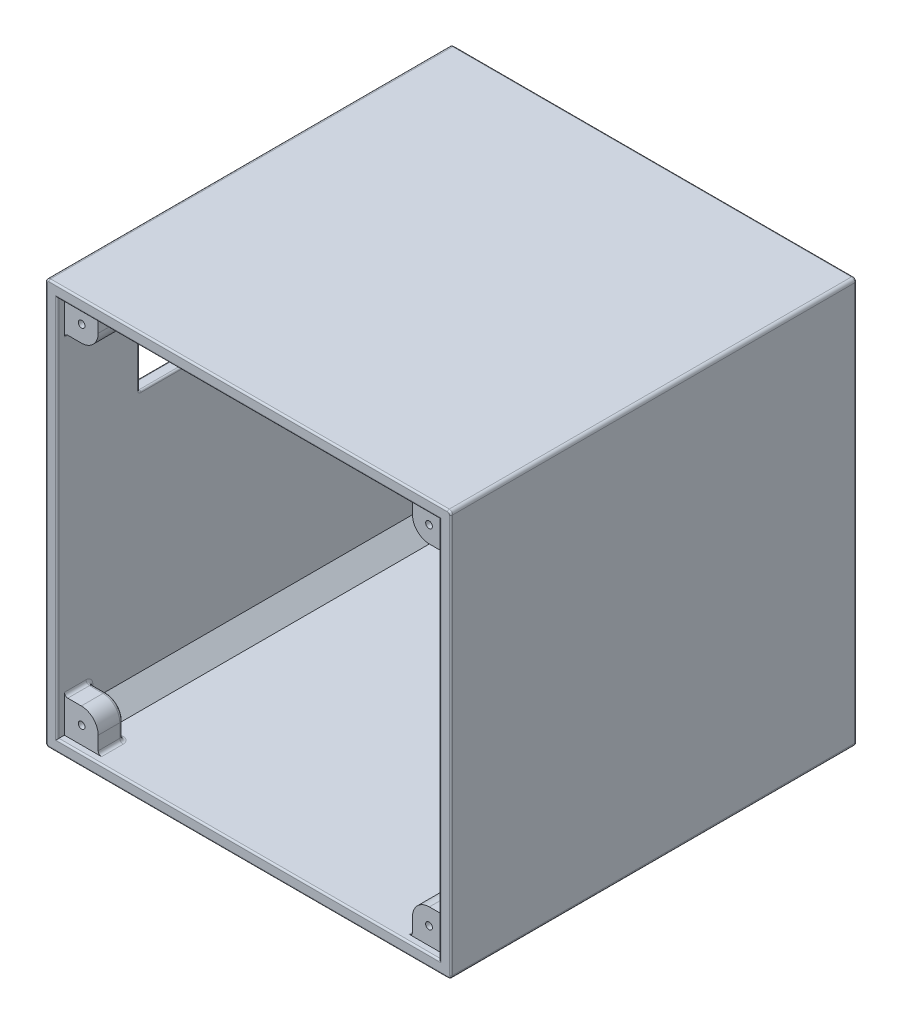
from build123d import *

# Parameters (mm, degrees)
ESBO_O2_W                     = 120
ESBO_O2_H                     = 120
RESSALTO_EXTRUS_O1_DEPTH      = 120
ESBO_O3_W                     = 113
ESBO_O3_H                     = 113
CORTE_EXTRUS_O1_DEPTH         = 120
RESSALTO_EXTRUS_O2_DEPTH      = 7
RESSALTO_EXTRUS_O6_DEPTH      = 7
CHANFRO1_SIZE                 = 5
CHANFRO2_SIZE                 = 5
ESBO_O14_W                    = 71.5
ESBO_O14_H                    = 24.5
CORTE_EXTRUS_O6_DEPTH         = 10
ESBO_O15_W                    = 113
ESBO_O15_H                    = 113
CORTE_EXTRUS_O7_DEPTH         = 5
FILETE3_R                     = 1
FILETE4_R                     = 1
RESSALTO_EXTRUS_O7_DEPTH      = 1.4
RESSALTO_EXTRUS_O7_DEPTH_BACK = 6
FILETE8_R                     = 1
ESBO_O16_R                    = 1
CORTE_EXTRUS_O8_DEPTH         = 7.4
ESPELHAR2_COPY_1_SKETCH_R     = 1
ESPELHAR2_COPY_1_DEPTH        = 7.4
ESBO_O17_R                    = 1.75
CORTE_EXTRUS_O9_DEPTH         = 7
ESBO_O18_R                    = 3.6
CORTE_EXTRUS_O10_DEPTH        = 1
ESPELHAR6_COPY_1_SKETCH_R     = 1.75
ESPELHAR6_COPY_1_DEPTH        = 7
ESPELHAR6_COPY_2_SKETCH_R     = 3.6
ESPELHAR6_COPY_2_DEPTH        = 1
ESBO_O19_R                    = 3.6
CORTE_EXTRUS_O12_DEPTH        = 0.5
ESBO_O21_R                    = 1.75
CORTE_EXTRUS_O13_DEPTH        = 7.5
FILETE9_R                     = 0.5


with BuildPart() as part:
    # Esboço2 → Ressalto-extrusão1 (new body)
    with BuildSketch(Plane.XY):
        Rectangle(ESBO_O2_W, ESBO_O2_H)
    extrude(amount=RESSALTO_EXTRUS_O1_DEPTH)

    # Esboço3 → Corte-extrusão1 (cut)
    with BuildSketch(Plane.XY.offset(120)):
        Rectangle(ESBO_O3_W, ESBO_O3_H)
    extrude(amount=-CORTE_EXTRUS_O1_DEPTH, mode=Mode.SUBTRACT)

    # Esboço4 → Ressalto-extrusão2 (add)
    with BuildSketch(Plane.XY):
        with BuildLine():
            Line((-51.5, 46.5), (-56.5, 46.5))
            Line((-56.5, 46.5), (-56.5, 56.5))
            Line((-56.5, 56.5), (-46.5, 56.5))
            Line((-46.5, 56.5), (-46.5, 51.5))
            ThreePointArc((-46.5, 51.5), (-47.964466094, 47.964466094), (-51.5, 46.5))
        make_face()
        with BuildLine():
            Line((46.5, 56.5), (46.5, 51.5))
            ThreePointArc((46.5, 51.5), (47.964466094, 47.964466094), (51.5, 46.5))
            Line((51.5, 46.5), (56.5, 46.5))
            Line((56.5, 46.5), (56.5, 56.5))
            Line((56.5, 56.5), (46.5, 56.5))
        make_face()
        with BuildLine():
            Line((51.5, -46.5), (56.5, -46.5))
            Line((56.5, -46.5), (56.5, -56.5))
            Line((56.5, -56.5), (46.5, -56.5))
            Line((46.5, -56.5), (46.5, -51.5))
            ThreePointArc((46.5, -51.5), (47.964466094, -47.964466094), (51.5, -46.5))
        make_face()
        with BuildLine():
            Line((-46.5, -56.5), (-46.5, -51.5))
            ThreePointArc((-46.5, -51.5), (-47.964466094, -47.964466094), (-51.5, -46.5))
            Line((-51.5, -46.5), (-56.5, -46.5))
            Line((-56.5, -46.5), (-56.5, -56.5))
            Line((-56.5, -56.5), (-46.5, -56.5))
        make_face()
        with BuildLine():
            Line((-51.5, 5), (-56.5, 5))
            Line((-56.5, 5), (-56.5, -5))
            Line((-56.5, -5), (-51.5, -5))
            ThreePointArc((-51.5, -5), (-46.5, 0), (-51.5, 5))
        make_face()
        with BuildLine():
            Line((56.5, -5), (51.5, -5))
            ThreePointArc((51.5, -5), (46.5, 0), (51.5, 5))
            Line((51.5, 5), (56.5, 5))
            Line((56.5, 5), (56.5, -5))
        make_face()
        with BuildLine():
            Line((-5, 51.5), (-5, 56.5))
            Line((-5, 56.5), (5, 56.5))
            Line((5, 56.5), (5, 51.5))
            ThreePointArc((5, 51.5), (0, 46.5), (-5, 51.5))
        make_face()
    extrude(amount=RESSALTO_EXTRUS_O2_DEPTH)

    # Esboço13 → Ressalto-extrusão6 (add)
    with BuildSketch(Plane.XY):
        with BuildLine():
            Line((-5, -51.5), (-5, -56.5))
            Line((-5, -56.5), (5, -56.5))
            Line((5, -56.5), (5, -51.5))
            ThreePointArc((5, -51.5), (0, -46.5), (-5, -51.5))
        make_face()
    extrude(amount=RESSALTO_EXTRUS_O6_DEPTH)

    # Chanfro1
    chanfro1_edges = [part.edges().sort_by_distance(p)[0] for p in [
        (-56.5, 56.5, 63.5),
    ]]
    chamfer(chanfro1_edges, length=CHANFRO1_SIZE)

    # Chanfro2
    chanfro2_edges = [part.edges().sort_by_distance(p)[0] for p in [
        (56.5, 56.5, 63.5),
        (56.5, -56.5, 63.5),
        (-56.5, -56.5, 63.5),
    ]]
    chamfer(chanfro2_edges, length=CHANFRO2_SIZE)

    # Esboço14 → Corte-extrusão6 (cut)
    with BuildSketch(Plane.ZY.offset(60)):
        with Locations((60, 32.75)):
            Rectangle(ESBO_O14_W, ESBO_O14_H)
    extrude(amount=-CORTE_EXTRUS_O6_DEPTH, mode=Mode.SUBTRACT)

    # Esboço15 → Corte-extrusão7 (cut)
    with BuildSketch(Plane.XY.offset(120)):
        Rectangle(ESBO_O15_W, ESBO_O15_H)
    extrude(amount=-CORTE_EXTRUS_O7_DEPTH, mode=Mode.SUBTRACT)

    # Filete3
    filete3_edges = [part.edges().sort_by_distance(p)[0] for p in [
        (-60, 60, 60),
    ]]
    fillet(filete3_edges, radius=FILETE3_R)

    # Filete4
    filete4_edges = [part.edges().sort_by_distance(p)[0] for p in [
        (60, -60, 60),
        (-60, -60, 60),
        (60, 60, 60),
    ]]
    fillet(filete4_edges, radius=FILETE4_R)

    # Esboço5 → Ressalto-extrusão7 (add, two sides)
    with BuildSketch(Plane.XY.offset(116.5)) as ressalto_extrus_o7_sk:
        with BuildLine():
            Line((-51.5, 46.5), (-56.5, 46.5))
            Line((-56.5, 46.5), (-56.5, 56.5))
            Line((-56.5, 56.5), (-46.5, 56.5))
            Line((-46.5, 56.5), (-46.5, 51.5))
            ThreePointArc((-46.5, 51.5), (-47.964466094, 47.964466094), (-51.5, 46.5))
        make_face()
        with BuildLine():
            Line((46.5, 56.5), (46.5, 51.5))
            ThreePointArc((46.5, 51.5), (47.964466094, 47.964466094), (51.5, 46.5))
            Line((51.5, 46.5), (56.5, 46.5))
            Line((56.5, 46.5), (56.5, 56.5))
            Line((56.5, 56.5), (46.5, 56.5))
        make_face()
        with BuildLine():
            Line((51.5, -46.5), (56.5, -46.5))
            Line((56.5, -46.5), (56.5, -56.5))
            Line((56.5, -56.5), (46.5, -56.5))
            Line((46.5, -56.5), (46.5, -51.5))
            ThreePointArc((46.5, -51.5), (47.964466094, -47.964466094), (51.5, -46.5))
        make_face()
        with BuildLine():
            Line((-46.5, -56.5), (-46.5, -51.5))
            ThreePointArc((-46.5, -51.5), (-47.964466094, -47.964466094), (-51.5, -46.5))
            Line((-51.5, -46.5), (-56.5, -46.5))
            Line((-56.5, -46.5), (-56.5, -56.5))
            Line((-56.5, -56.5), (-46.5, -56.5))
        make_face()
    extrude(amount=RESSALTO_EXTRUS_O7_DEPTH)
    extrude(ressalto_extrus_o7_sk.sketch, amount=-RESSALTO_EXTRUS_O7_DEPTH_BACK)

    # Filete8
    filete8_edges = [part.edges().sort_by_distance(p)[0] for p in [
        (56.5, -5, 3.5),
        (56.5, 5, 3.5),
        (46.5, 0, 7),
        (54, -5, 7),
        (56.5, 0, 7),
        (54, 5, 7),
        (5, 56.5, 3.5),
        (-5, 56.5, 3.5),
        (5, 54, 7),
        (0, 56.5, 7),
        (-5, 54, 7),
        (0, 46.5, 7),
        (-5, -56.5, 3.5),
        (5, -56.5, 3.5),
        (0, -46.5, 7),
        (-5, -54, 7),
        (0, -56.5, 7),
        (5, -54, 7),
        (-56.5, 49, 7),
        (-54, 54, 7),
        (-49, -56.5, 7),
        (-54, -54, 7),
        (56.5, -49, 7),
        (54, -54, 7),
        (49, 56.5, 7),
        (54, 54, 7),
        (-54, 54, 110.5),
        (-49, 56.5, 110.5),
        (-46.5, 56.5, 114.2),
        (-56.5, 49, 110.5),
        (-47.964466094, 47.964466094, 110.5),
        (-46.5, 54, 110.5),
        (-56.5, 46.5, 114.2),
        (-54, 46.5, 110.5),
        (54, 54, 110.5),
        (56.5, 49, 110.5),
        (56.5, 46.5, 114.2),
        (49, 56.5, 110.5),
        (47.964466094, 47.964466094, 110.5),
        (54, 46.5, 110.5),
        (46.5, 56.5, 114.2),
        (46.5, 54, 110.5),
        (54, -54, 110.5),
        (49, -56.5, 110.5),
        (46.5, -56.5, 114.2),
        (56.5, -49, 110.5),
        (47.964466094, -47.964466094, 110.5),
        (46.5, -54, 110.5),
        (56.5, -46.5, 114.2),
        (54, -46.5, 110.5),
        (-54, -54, 110.5),
        (-56.5, -49, 110.5),
        (-56.5, -46.5, 114.2),
        (-49, -56.5, 110.5),
        (-47.964466094, -47.964466094, 110.5),
        (-54, -46.5, 110.5),
        (-46.5, -56.5, 114.2),
        (-46.5, -54, 110.5),
        (-46.5, 56.5, 3.5),
        (-56.5, 46.5, 3.5),
        (-47.964466094, 47.964466094, 7),
        (-46.5, 54, 7),
        (-49, 56.5, 7),
        (-54, 46.5, 7),
        (56.5, 46.5, 3.5),
        (46.5, 56.5, 3.5),
        (47.964466094, 47.964466094, 7),
        (54, 46.5, 7),
        (56.5, 49, 7),
        (46.5, 54, 7),
        (46.5, -56.5, 3.5),
        (56.5, -46.5, 3.5),
        (47.964466094, -47.964466094, 7),
        (46.5, -54, 7),
        (49, -56.5, 7),
        (54, -46.5, 7),
        (-56.5, -46.5, 3.5),
        (-46.5, -56.5, 3.5),
        (-47.964466094, -47.964466094, 7),
        (-54, -46.5, 7),
        (-56.5, -49, 7),
        (-46.5, -54, 7),
        (-56.5, 5, 3.5),
        (-56.5, -5, 3.5),
        (-46.5, 0, 7),
        (-54, 5, 7),
        (-56.5, 0, 7),
        (-54, -5, 7),
    ]]
    fillet(filete8_edges, radius=FILETE8_R)

    # Esboço16 → Corte-extrusão8 (cut)
    with BuildSketch(Plane.XY.offset(117.9)):
        with Locations((-51.4, 51.4)):
            Circle(ESBO_O16_R)
    corte_extrus_o8 = extrude(amount=-CORTE_EXTRUS_O8_DEPTH, mode=Mode.SUBTRACT)

    # Espelhar1: Corte-extrusão8 across plane
    add(corte_extrus_o8.mirror(Plane.ZX), mode=Mode.SUBTRACT)

    # Espelhar2: Corte-extrusão8 across plane
    add(corte_extrus_o8.mirror(Plane(origin=(0, 0, 0), x_dir=(0, 0, 1), z_dir=(1, 0, 0))), mode=Mode.SUBTRACT)

    # Espelhar2 copy 1 sketch → Espelhar2 copy 1 (cut)
    with BuildSketch(Plane(origin=(0, 0, 117.9), x_dir=(-1, 0, 0), z_dir=(0, 0, 1))):
        with Locations((-51.4, 51.4)):
            Circle(ESPELHAR2_COPY_1_SKETCH_R)
    extrude(amount=-ESPELHAR2_COPY_1_DEPTH, mode=Mode.SUBTRACT)

    # Esboço17 → Corte-extrusão9 (cut)
    with BuildSketch(Plane.XY.offset(7)):
        with Locations((-51.4, 51.4)):
            Circle(ESBO_O17_R)
    corte_extrus_o9 = extrude(amount=-CORTE_EXTRUS_O9_DEPTH, mode=Mode.SUBTRACT)

    # Esboço18 → Corte-extrusão10 (cut, symmetric)
    with BuildSketch(Plane.XY.offset(7)):
        with Locations((-51.4, 51.4)):
            Circle(ESBO_O18_R)
    corte_extrus_o10 = extrude(amount=CORTE_EXTRUS_O10_DEPTH, both=True, mode=Mode.SUBTRACT)

    # Espelhar5: Corte-extrusão9, Corte-extrusão10 across plane
    add(corte_extrus_o9.mirror(Plane.ZX), mode=Mode.SUBTRACT)
    add(corte_extrus_o10.mirror(Plane.ZX), mode=Mode.SUBTRACT)

    # Espelhar6: Corte-extrusão9, Corte-extrusão10 across plane
    add(corte_extrus_o9.mirror(Plane(origin=(0, 0, 0), x_dir=(0, 0, 1), z_dir=(1, 0, 0))), mode=Mode.SUBTRACT)
    add(corte_extrus_o10.mirror(Plane(origin=(0, 0, 0), x_dir=(0, 0, 1), z_dir=(1, 0, 0))), mode=Mode.SUBTRACT)

    # Espelhar6 copy 1 sketch → Espelhar6 copy 1 (cut)
    with BuildSketch(Plane(origin=(0, 0, 7), x_dir=(-1, 0, 0), z_dir=(0, 0, 1))):
        with Locations((-51.4, 51.4)):
            Circle(ESPELHAR6_COPY_1_SKETCH_R)
    extrude(amount=-ESPELHAR6_COPY_1_DEPTH, mode=Mode.SUBTRACT)

    # Espelhar6 copy 2 sketch → Espelhar6 copy 2 (cut, symmetric)
    with BuildSketch(Plane(origin=(0, 0, 7), x_dir=(-1, 0, 0), z_dir=(0, 0, 1))):
        with Locations((-51.4, 51.4)):
            Circle(ESPELHAR6_COPY_2_SKETCH_R)
    extrude(amount=ESPELHAR6_COPY_2_DEPTH, both=True, mode=Mode.SUBTRACT)

    # Esboço19 → Corte-extrusão12 (cut)
    with BuildSketch(Plane.XY.offset(7)):
        with Locations((-51.4, 0)):
            Circle(ESBO_O19_R)
        with Locations((0, 51.4)):
            Circle(ESBO_O19_R)
        with Locations((51.4, 0)):
            Circle(ESBO_O19_R)
        with Locations((0, -51.4)):
            Circle(ESBO_O19_R)
    extrude(amount=-CORTE_EXTRUS_O12_DEPTH, mode=Mode.SUBTRACT)

    # Esboço21 → Corte-extrusão13 (cut, through all)
    with BuildSketch(Plane.XY.offset(6.5)):
        with Locations((-51.4, 0)):
            Circle(ESBO_O21_R)
        with Locations((0, 51.4)):
            Circle(ESBO_O21_R)
        with Locations((51.4, 0)):
            Circle(ESBO_O21_R)
        with Locations((0, -51.4)):
            Circle(ESBO_O21_R)
    extrude(amount=-CORTE_EXTRUS_O13_DEPTH, mode=Mode.SUBTRACT)

    # Filete9
    filete9_edges = [part.edges().sort_by_distance(p)[0] for p in [
        (5, 53.5, 0),
        (0, 46.5, 0),
        (0, -46.5, 0),
        (-5, -53.5, 0),
        (-56.5, 0, 120),
        (0, -56.5, 120),
        (56.5, 0, 120),
        (0, 56.5, 120),
        (-56.5, 32.75, 95.75),
        (-58.25, 45, 95.75),
        (-56.5, 20.5, 60),
        (-58.25, 20.5, 95.75),
        (-56.5, 32.75, 24.25),
        (-58.25, 20.5, 24.25),
        (-56.5, 45, 60),
        (-58.25, 45, 24.25),
        (-60, 32.75, 95.75),
        (-60, 45, 60),
        (-60, 32.75, 24.25),
        (-60, 20.5, 60),
        (-60, 0, 0),
        (-60, 0, 120),
        (-59.707106781, 59.707106781, 0),
        (-59.707106781, 59.707106781, 120),
        (0, 60, 0),
        (0, 60, 120),
        (60, 0, 0),
        (0, -60, 0),
        (-59.707106781, -59.707106781, 0),
        (59.707106781, -59.707106781, 0),
        (59.707106781, 59.707106781, 0),
        (60, 0, 120),
        (0, -60, 120),
        (-59.707106781, -59.707106781, 120),
        (59.707106781, -59.707106781, 120),
        (59.707106781, 59.707106781, 120),
        (-47.964466094, 47.964466094, 0),
        (-46.5, 53.5, 0),
        (56.5, 25.75, 0),
        (56.5, -25.75, 0),
        (25.75, -56.5, 0),
        (-25.75, -56.5, 0),
        (-56.5, -25.75, 0),
        (-56.5, 25.75, 0),
        (-25.75, 56.5, 0),
        (25.75, 56.5, 0),
        (53.5, 5, 0),
        (53.5, -46.5, 0),
        (5, -53.5, 0),
        (-46.5, -53.5, 0),
        (-53.5, -5, 0),
        (-53.5, 46.5, 0),
        (-5, 53.5, 0),
        (46.5, 53.5, 0),
        (47.964466094, 47.964466094, 0),
        (53.5, 46.5, 0),
        (56.207106781, 5.292893219, 0),
        (56.207106781, -5.292893219, 0),
        (46.207106781, -56.207106781, 0),
        (56.207106781, -46.207106781, 0),
        (5.292893219, -56.207106781, 0),
        (-5.292893219, -56.207106781, 0),
        (-56.207106781, -46.207106781, 0),
        (-46.207106781, -56.207106781, 0),
        (-56.207106781, -5.292893219, 0),
        (-56.207106781, 5.292893219, 0),
        (-46.207106781, 56.207106781, 0),
        (-56.207106781, 46.207106781, 0),
        (-5.292893219, 56.207106781, 0),
        (5.292893219, 56.207106781, 0),
        (56.207106781, 46.207106781, 0),
        (46.207106781, 56.207106781, 0),
        (47.964466094, -47.964466094, 0),
        (46.5, -53.5, 0),
        (-47.964466094, -47.964466094, 0),
        (-53.5, -46.5, 0),
        (-53.15, 51.4, 0),
        (-53.15, -51.4, 0),
        (53.15, -51.4, 0),
        (53.15, 51.4, 0),
        (-53.15, 0, 0),
        (-1.75, 51.4, 0),
        (49.65, 0, 0),
        (-1.75, -51.4, 0),
        (-46.5, 0, 0),
        (-53.5, 5, 0),
        (46.5, 0, 0),
        (53.5, -5, 0),
    ]]
    fillet(filete9_edges, radius=FILETE9_R)


solid = part.part
